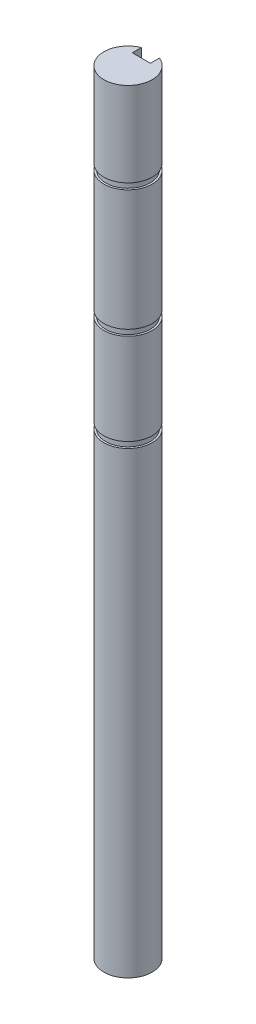
from build123d import *

# Parameters (mm, degrees)
BOSS_EXTRUDE1_DEPTH = 101.6
CUT_EXTRUDE1_START  = -41.3258
SKETCH3_R           = 3.175
SKETCH3_R_2         = 2.921
CUT_EXTRUDE1_DEPTH  = 0.7874
CUT_EXTRUDE2_START  = -28.5496
SKETCH3_3_R         = 3.175
SKETCH3_3_R_2       = 2.921
CUT_EXTRUDE2_DEPTH  = 0.7874
CUT_EXTRUDE3_START  = -11.8872
SKETCH3_4_R         = 3.175
SKETCH3_4_R_2       = 2.921
CUT_EXTRUDE3_DEPTH  = 0.7874


with BuildPart() as part:
    # Sketch1 → Boss-Extrude1 (new body)
    with BuildSketch(Plane(origin=(0, 0, 0), x_dir=(1, 0, 0), z_dir=(0, 1, 0))):
        with BuildLine():
            Line((-1.190625, 2.943303775), (-1.190625, 1.752678775))
            Line((-1.190625, 1.752678775), (1.190625, 1.752678775))
            Line((1.190625, 1.752678775), (1.190625, 2.943303775))
            ThreePointArc((1.190625, 2.943303775), (0, -3.175), (-1.190625, 2.943303775))
        make_face()
    extrude(amount=BOSS_EXTRUDE1_DEPTH)

    # Sketch3 → Cut-Extrude1 (cut)
    with BuildSketch(Plane(origin=(0, 101.6, 0), x_dir=(1, 0, 0), z_dir=(0, 1, 0)).offset(CUT_EXTRUDE1_START)):
        Circle(SKETCH3_R)
        Circle(SKETCH3_R_2, mode=Mode.SUBTRACT)
    extrude(amount=CUT_EXTRUDE1_DEPTH, mode=Mode.SUBTRACT)

    # Sketch3_3 → Cut-Extrude2 (cut)
    with BuildSketch(Plane(origin=(0, 101.6, 0), x_dir=(1, 0, 0), z_dir=(0, 1, 0)).offset(CUT_EXTRUDE2_START)):
        Circle(SKETCH3_3_R)
        Circle(SKETCH3_3_R_2, mode=Mode.SUBTRACT)
    extrude(amount=CUT_EXTRUDE2_DEPTH, mode=Mode.SUBTRACT)

    # Sketch3_4 → Cut-Extrude3 (cut)
    with BuildSketch(Plane(origin=(0, 101.6, 0), x_dir=(1, 0, 0), z_dir=(0, 1, 0)).offset(CUT_EXTRUDE3_START)):
        Circle(SKETCH3_4_R)
        Circle(SKETCH3_4_R_2, mode=Mode.SUBTRACT)
    extrude(amount=CUT_EXTRUDE3_DEPTH, mode=Mode.SUBTRACT)


solid = part.part
